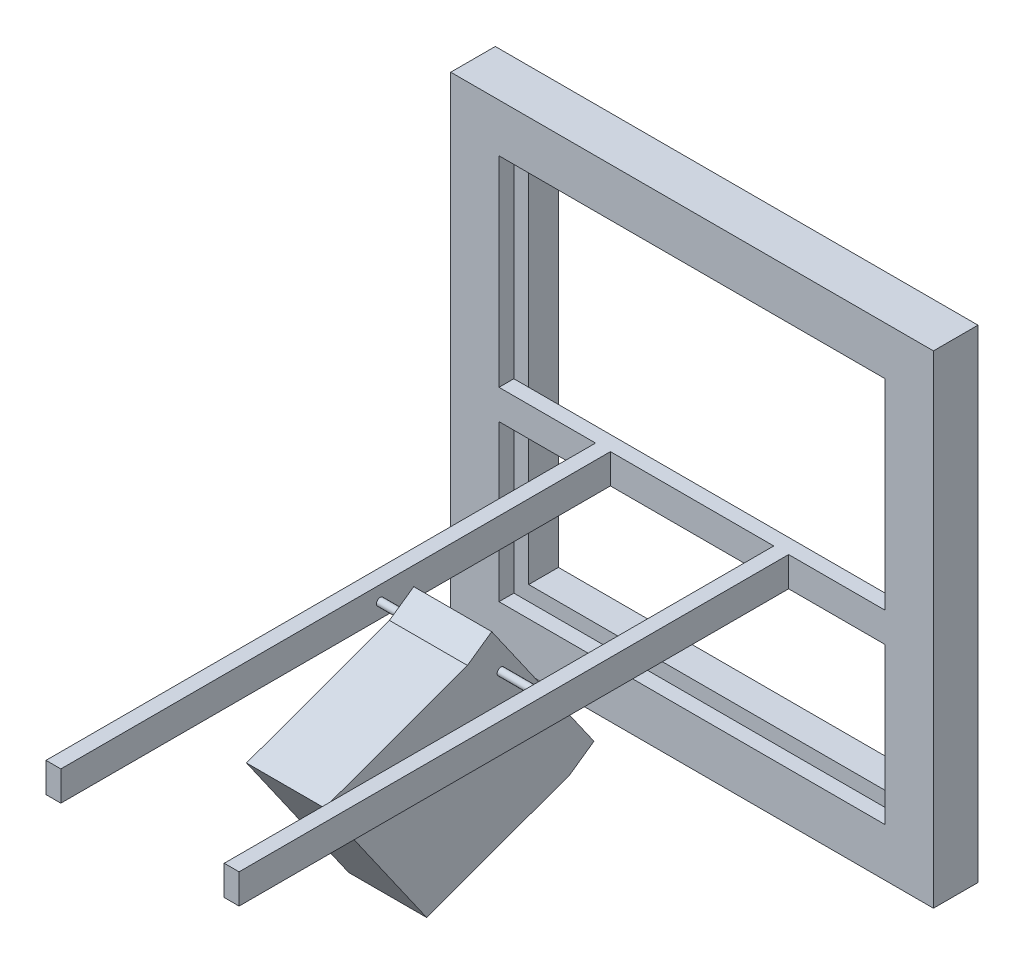
from build123d import *

# Parameters (mm, degrees)
SKETCH1_W           = 660.4
SKETCH1_H           = 660.4
SKETCH1_W_2         = 609.6
SKETCH1_H_2         = 609.6
BOSS_EXTRUDE1_DEPTH = 50.8
SKETCH2_W           = 660.4
SKETCH2_H           = 50.8
BOSS_EXTRUDE2_DEPTH = 25.4
SKETCH3_W           = 25.4
SKETCH3_H           = 50.8
BOSS_EXTRUDE3_DEPTH = 939.8
BOSS_EXTRUDE4_START = 73.025
SKETCH4_R           = 6.35
BOSS_EXTRUDE4_DEPTH = 133.35
SKETCH4_2_R         = 6.35
BOSS_EXTRUDE5_DEPTH = 282.956
SKETCH5_W           = 825.5
SKETCH5_H           = 825.5
SKETCH5_W_2         = 660.4
SKETCH5_H_2         = 660.4
BOSS_EXTRUDE6_DEPTH = 76.2


with BuildPart() as part:
    # Sketch1 → Boss-Extrude1 (new body)
    with BuildSketch(Plane.XY):
        with Locations((330.2, 330.2)):
            Rectangle(SKETCH1_W, SKETCH1_H)
        with Locations((330.2, 330.2)):
            Rectangle(SKETCH1_W_2, SKETCH1_H_2, mode=Mode.SUBTRACT)
    extrude(amount=BOSS_EXTRUDE1_DEPTH)

    # Sketch2 → Boss-Extrude2 (add)
    with BuildSketch(Plane.XY.offset(50.8)):
        with Locations((330.2, 292.1)):
            Rectangle(SKETCH2_W, SKETCH2_H)
    extrude(amount=BOSS_EXTRUDE2_DEPTH)

    # Sketch3 → Boss-Extrude3 (add)
    with BuildSketch(Plane.XY.offset(76.2)):
        with Locations((177.8, 292.1)):
            Rectangle(SKETCH3_W, SKETCH3_H)
        with Locations((482.6, 292.1)):
            Rectangle(SKETCH3_W, SKETCH3_H)
    extrude(amount=BOSS_EXTRUDE3_DEPTH)



with BuildPart() as body_2:
    # Sketch4 → Boss-Extrude4 (new body)
    with BuildSketch(Plane.ZY.offset(-469.9).offset(BOSS_EXTRUDE4_START)):
        Polygon((485.515641783, 358.684996296), (310.689543984, 109.007453196), (352.302467833, 79.86977023), (596.712759729, -9.088300969), (771.538857529, 240.589242131), (527.128565633, 329.547313329), align=None)
        with Locations((469.9, 292.1)):
            Circle(SKETCH4_R, mode=Mode.SUBTRACT)
    extrude(amount=BOSS_EXTRUDE4_DEPTH)


with BuildPart() as part_1:
    add(part.part)

    add(body_2.part)  # Boss-Extrude5 merges body 2
    # Sketch4_2 → Boss-Extrude5 (add)
    with BuildSketch(Plane.ZY.offset(-469.9)):
        with Locations((469.9, 292.1)):
            Circle(SKETCH4_2_R)
    extrude(amount=BOSS_EXTRUDE5_DEPTH)

    # Sketch5 → Boss-Extrude6 (add)
    with BuildSketch(Plane.XY):
        with Locations((330.2, 330.2)):
            Rectangle(SKETCH5_W, SKETCH5_H)
        with Locations((330.2, 330.2)):
            Rectangle(SKETCH5_W_2, SKETCH5_H_2, mode=Mode.SUBTRACT)
    extrude(amount=BOSS_EXTRUDE6_DEPTH)


solid = part_1.part
